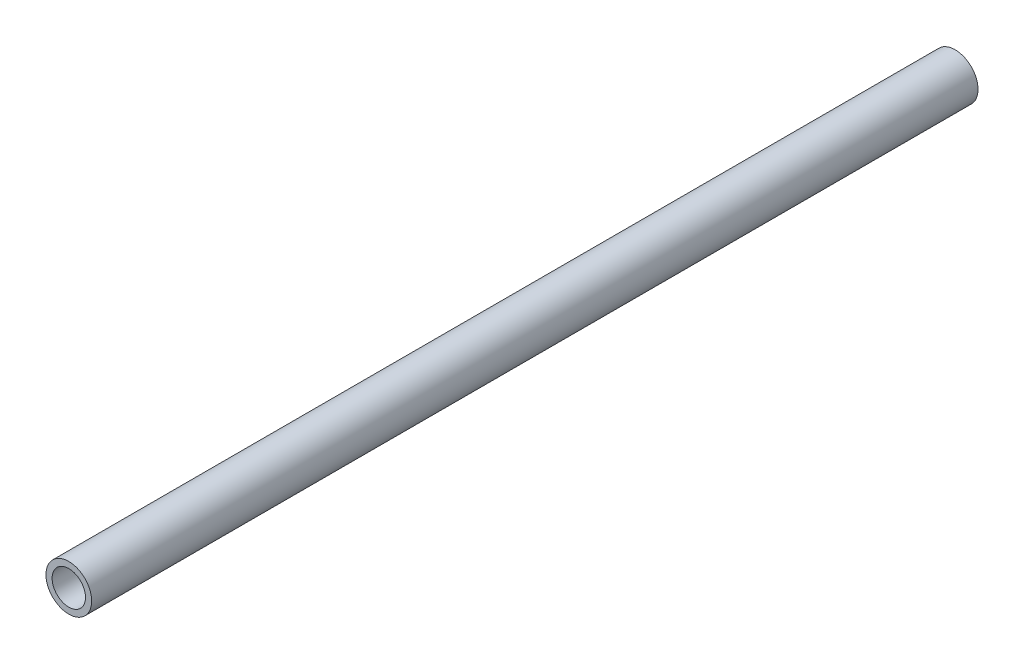
from build123d import *

# Parameters (mm, degrees)
CROQUIS1_R              = 10.7
CROQUIS1_R_2            = 7.825
SALIENTE_EXTRUIR1_DEPTH = 207.5


with BuildPart() as part:
    # Croquis1 → Saliente-Extruir1 (new body, symmetric)
    with BuildSketch(Plane.XY):
        Circle(CROQUIS1_R)
        Circle(CROQUIS1_R_2, mode=Mode.SUBTRACT)
    extrude(amount=SALIENTE_EXTRUIR1_DEPTH, both=True)


solid = part.part
